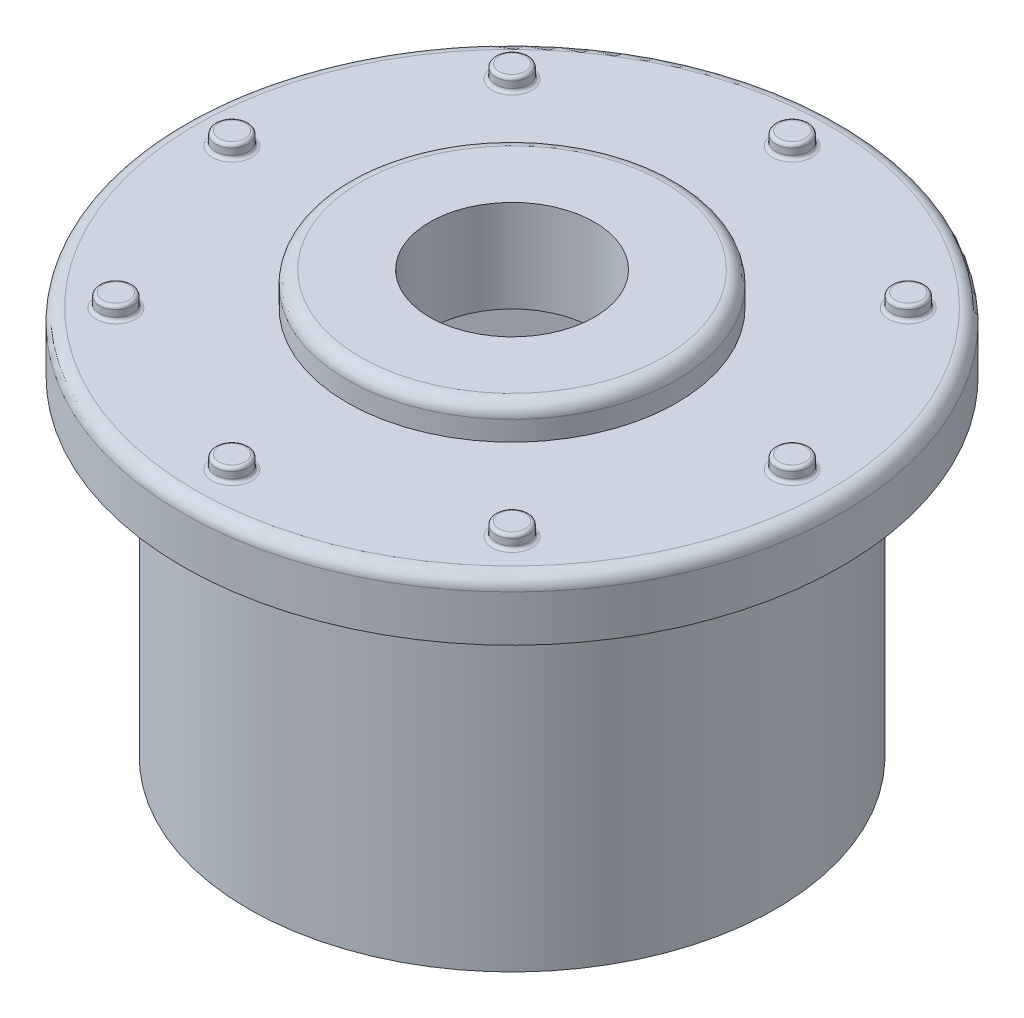
from build123d import *

# Parameters (mm, degrees)
SKETCH2_R                = 5
BOSS_EXTRUDE1_DEPTH      = 0.9
SKETCH13_R               = 0.25
BOSS_EXTRUDE4_DEPTH      = 0.2
FILLET3_R                = 0.05
CIRPATTERN3_COUNT        = 8
FILLET3_OF_CIRPATTERN3_R = 0.05
SKETCH36_R               = 4
BOSS_EXTRUDE5_DEPTH      = 5
SKETCH37_R               = 3
CUT_EXTRUDE5_DEPTH       = 6
BOSS_EXTRUDE7_DEPTH      = 4.5
BOSS_EXTRUDE7_2_DEPTH    = 4.5
BOSS_EXTRUDE7_3_DEPTH    = 4.5
BOSS_EXTRUDE7_4_DEPTH    = 4.5
BOSS_EXTRUDE7_5_DEPTH    = 4.5
BOSS_EXTRUDE7_6_DEPTH    = 4.5
SKETCH39_R               = 2.5
BOSS_EXTRUDE8_DEPTH      = 0.5
SKETCH40_R               = 1.25
CUT_EXTRUDE6_DEPTH       = 7.4
FILLET4_R                = 0.2


with BuildPart() as part:
    # Sketch2 → Boss-Extrude1 (new body)
    with BuildSketch(Plane(origin=(0, 0, 0), x_dir=(1, 0, 0), z_dir=(0, 1, 0))):
        Circle(SKETCH2_R)
    extrude(amount=BOSS_EXTRUDE1_DEPTH)

    # Sketch13 → Boss-Extrude4 (add)
    with BuildSketch(Plane(origin=(0, 0.9, 0), x_dir=(1, 0, 0), z_dir=(0, 1, 0))):
        with Locations((-4.25, 0)):
            Circle(SKETCH13_R)
    boss_extrude4 = extrude(amount=BOSS_EXTRUDE4_DEPTH)

    # Fillet3
    fillet3_edges = [part.edges().sort_by_distance(p)[0] for p in [
        (-4.5, 0.9, 0),
        (-4.5, 1.1, 0),
    ]]
    fillet(fillet3_edges, radius=FILLET3_R)

    # CirPattern3: Boss-Extrude4 ×8 about axis
    cirpattern3_axis = Axis((0, 0, 0), (0, 1, 0))
    for i in range(1, CIRPATTERN3_COUNT):
        add(boss_extrude4.rotate(cirpattern3_axis, i * 360 / CIRPATTERN3_COUNT))

    # Fillet3 of CirPattern3
    fillet3_of_cirpattern3_edges = [part.edges().sort_by_distance(p)[0] for p in [
        (-3.181980515, 0.9, 3.181980515),
        (-3.181980515, 1.1, 3.181980515),
        (0, 0.9, 4.5),
        (0, 1.1, 4.5),
        (3.181980515, 0.9, 3.181980515),
        (3.181980515, 1.1, 3.181980515),
        (4.5, 0.9, 0),
        (4.5, 1.1, 0),
        (3.181980515, 0.9, -3.181980515),
        (3.181980515, 1.1, -3.181980515),
        (0, 0.9, -4.5),
        (0, 1.1, -4.5),
        (-3.181980515, 0.9, -3.181980515),
        (-3.181980515, 1.1, -3.181980515),
    ]]
    fillet(fillet3_of_cirpattern3_edges, radius=FILLET3_OF_CIRPATTERN3_R)

    # Sketch36 → Boss-Extrude5 (add)
    with BuildSketch(Plane(origin=(0, 0, 0), x_dir=(1, 0, 0), z_dir=(0, 1, 0))):
        Circle(SKETCH36_R)
    extrude(amount=-BOSS_EXTRUDE5_DEPTH)

    # Sketch37 → Cut-Extrude5 (cut, through all)
    with BuildSketch(Plane(origin=(0, 0, 0), x_dir=(1, 0, 0), z_dir=(0, 1, 0))):
        Circle(SKETCH37_R)
    extrude(amount=-CUT_EXTRUDE5_DEPTH, mode=Mode.SUBTRACT)

    # Sketch39 → Boss-Extrude8 (add)
    with BuildSketch(Plane(origin=(0, 0.9, 0), x_dir=(1, 0, 0), z_dir=(0, 1, 0))):
        Circle(SKETCH39_R)
    extrude(amount=BOSS_EXTRUDE8_DEPTH)

    # Sketch40 → Cut-Extrude6 (cut, through all)
    with BuildSketch(Plane(origin=(0, 1.4, 0), x_dir=(1, 0, 0), z_dir=(0, 1, 0))):
        Circle(SKETCH40_R)
    extrude(amount=-CUT_EXTRUDE6_DEPTH, mode=Mode.SUBTRACT)

    # Fillet4
    fillet4_edges = [part.edges().sort_by_distance(p)[0] for p in [
        (-2.5, 1.4, 0),
        (-5, 0.9, 0),
    ]]
    fillet(fillet4_edges, radius=FILLET4_R)


with BuildPart() as body_2:
    # Sketch37_4 → Boss-Extrude7 (new body)
    with BuildSketch(Plane(origin=(0, 0, 0), x_dir=(1, 0, 0), z_dir=(0, 1, 0))):
        with BuildLine():
            Line((-2.598076211, 1.5), (0, 3))
            ThreePointArc((0, 3), (-1.5, 2.598076211), (-2.598076211, 1.5))
        make_face()
    extrude(amount=-BOSS_EXTRUDE7_DEPTH)


with BuildPart() as body_3:
    # Sketch37_4 → Boss-Extrude7 2 (new body)
    with BuildSketch(Plane(origin=(0, 0, 0), x_dir=(1, 0, 0), z_dir=(0, 1, 0))):
        with BuildLine():
            ThreePointArc((2.598076211, 1.5), (1.5, 2.598076211), (0, 3))
            Line((0, 3), (2.598076211, 1.5))
        make_face()
    extrude(amount=-BOSS_EXTRUDE7_2_DEPTH)


with BuildPart() as body_4:
    # Sketch37_4 → Boss-Extrude7 3 (new body)
    with BuildSketch(Plane(origin=(0, 0, 0), x_dir=(1, 0, 0), z_dir=(0, 1, 0))):
        with BuildLine():
            ThreePointArc((3, 0), (2.897777479, 0.776457135), (2.598076211, 1.5))
            Line((2.598076211, 1.5), (2.598076211, -1.5))
            ThreePointArc((2.598076211, -1.5), (2.897777479, -0.776457135), (3, 0))
        make_face()
    extrude(amount=-BOSS_EXTRUDE7_3_DEPTH)


with BuildPart() as body_5:
    # Sketch37_4 → Boss-Extrude7 4 (new body)
    with BuildSketch(Plane(origin=(0, 0, 0), x_dir=(1, 0, 0), z_dir=(0, 1, 0))):
        with BuildLine():
            ThreePointArc((0, -3), (1.5, -2.598076211), (2.598076211, -1.5))
            Line((2.598076211, -1.5), (0, -3))
        make_face()
    extrude(amount=-BOSS_EXTRUDE7_4_DEPTH)


with BuildPart() as body_6:
    # Sketch37_4 → Boss-Extrude7 5 (new body)
    with BuildSketch(Plane(origin=(0, 0, 0), x_dir=(1, 0, 0), z_dir=(0, 1, 0))):
        with BuildLine():
            Line((0, -3), (-2.598076211, -1.5))
            ThreePointArc((-2.598076211, -1.5), (-1.5, -2.598076211), (0, -3))
        make_face()
    extrude(amount=-BOSS_EXTRUDE7_5_DEPTH)


with BuildPart() as body_7:
    # Sketch37_4 → Boss-Extrude7 6 (new body)
    with BuildSketch(Plane(origin=(0, 0, 0), x_dir=(1, 0, 0), z_dir=(0, 1, 0))):
        with BuildLine():
            Line((-2.598076211, -1.5), (-2.598076211, 1.5))
            ThreePointArc((-2.598076211, 1.5), (-3, 0), (-2.598076211, -1.5))
        make_face()
    extrude(amount=-BOSS_EXTRUDE7_6_DEPTH)


solid = Compound([part.part, body_2.part, body_3.part, body_4.part, body_5.part, body_6.part, body_7.part])
